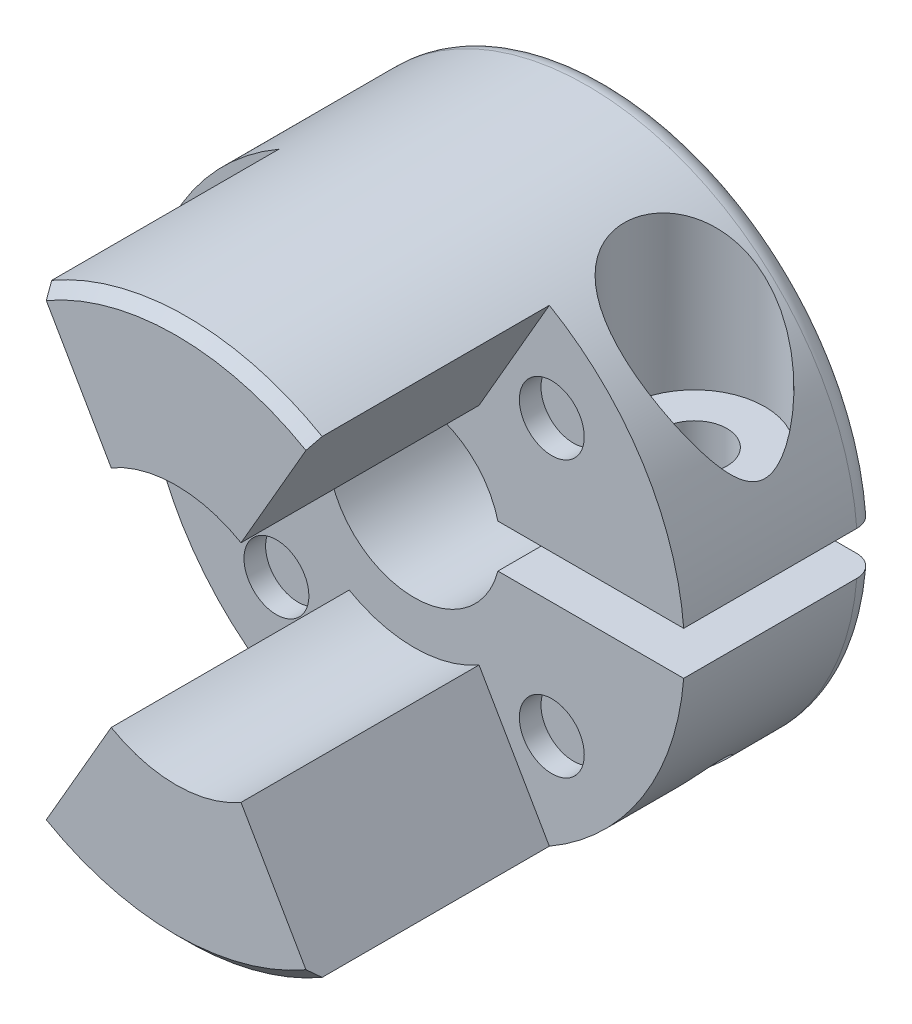
from build123d import *

# Parameters (mm, degrees)
ESBO_O1_R                 = 12.5
RESSALTO_EXTRUS_O1_DEPTH  = 20
CORTE_EXTRUS_O3_DEPTH     = 11
ESBO_O3_R                 = 4
CORTE_EXTRUS_O4_DEPTH     = 21
ESBO_O6_W                 = 12
ESBO_O6_H                 = 2
CORTE_EXTRUS_O5_DEPTH     = 10
CORTE_EXTRUS_O6_START     = -3
ESBO_O7_R                 = 3.25
CORTE_EXTRUS_O6_DEPTH     = 9.5
FURO_ROSCADO_DE_M3X0_51_D = 2.5
FILETE1_R                 = 1
ESBO_O10_R                = 1.5
CORTE_EXTRUS_O7_DEPTH     = 1
CHANFRO1_SIZE             = 0.5
CORTE_EXTRUS_O8_REACH     = 18.5
ESBO_O11_R                = 1.5
ESBO_O12_R                = 6
CORTE_EXTRUS_O9_DEPTH     = 11
PADR_OCIRCULAR1_COUNT     = 4
CHANFRO2_SIZE             = 0.5


with BuildPart() as part:
    # Esboço1 → Ressalto-extrusão1 (new body)
    with BuildSketch(Plane.XY):
        Circle(ESBO_O1_R)
    extrude(amount=RESSALTO_EXTRUS_O1_DEPTH)

    # Esboço2 → Corte-extrusão3 (cut)
    with BuildSketch(Plane.XY.offset(20)):
        with BuildLine():
            Line((0, 0), (6.25, 10.825317547))
            ThreePointArc((6.25, 10.825317547), (12.5, 0), (6.25, -10.825317547))
            Line((6.25, -10.825317547), (0, 0))
        make_face()
    corte_extrus_o3 = extrude(amount=-CORTE_EXTRUS_O3_DEPTH, mode=Mode.SUBTRACT)

    # Esboço3 → Corte-extrusão4 (cut, through all)
    with BuildSketch(Plane(origin=(0, 0, 0), x_dir=(-1, 0, 0), z_dir=(0, 0, -1))):
        Circle(ESBO_O3_R)
    extrude(amount=-CORTE_EXTRUS_O4_DEPTH, mode=Mode.SUBTRACT)

    # Espelhar1: Corte-extrusão3 across plane
    add(corte_extrus_o3.mirror(Plane(origin=(0, 0, 0), x_dir=(0, 0, 1), z_dir=(1, 0, 0))), mode=Mode.SUBTRACT)

    # Esboço6 → Corte-extrusão5 (cut, through all)
    with BuildSketch(Plane.XY.offset(9)):
        with Locations((7, 0)):
            Rectangle(ESBO_O6_W, ESBO_O6_H)
    extrude(amount=-CORTE_EXTRUS_O5_DEPTH, mode=Mode.SUBTRACT)

    # Esboço7 → Corte-extrusão6 (cut, through all)
    with BuildSketch(Plane.XZ.offset(-1).offset(CORTE_EXTRUS_O6_START)):
        with Locations((8.459935794, 4.5)):
            Circle(ESBO_O7_R)
    extrude(amount=-CORTE_EXTRUS_O6_DEPTH, mode=Mode.SUBTRACT)

    # Furo roscado de M3x0.51 (through all)
    with Locations(Plane(origin=(0, 4, 0), x_dir=(1, 0, 0), z_dir=(0, 1, 0))):
        with Locations((8.459935794, -4.5)):
            Hole(FURO_ROSCADO_DE_M3X0_51_D / 2)

    # Filete1
    filete1_edges = [part.edges().sort_by_distance(p)[0] for p in [
        (-12.5, 0, 0),
    ]]
    fillet(filete1_edges, radius=FILETE1_R)

    # Esboço10 → Corte-extrusão7 (cut)
    with BuildSketch(Plane.XY.offset(9)):
        with Locations((6.363961031, -6.363961031)):
            Circle(ESBO_O10_R)
    corte_extrus_o7 = extrude(amount=-CORTE_EXTRUS_O7_DEPTH, mode=Mode.SUBTRACT)

    # Chanfro1
    chanfro1_edges = [part.edges().sort_by_distance(p)[0] for p in [
        (0, -12.5, 20),
        (0, 12.5, 20),
    ]]
    chamfer(chanfro1_edges, length=CHANFRO1_SIZE)

    # Esboço11 → Corte-extrusão8 (cut, up to next)
    with BuildSketch(Plane(origin=(0, 4, 0), x_dir=(1, 0, 0), z_dir=(0, 1, 0)), mode=Mode.PRIVATE) as corte_extrus_o8_sk1:
        with Locations((8.459935794, -4.5)):
            Circle(ESBO_O11_R)
    corte_extrus_o8_tool1 = extrude(corte_extrus_o8_sk1.sketch, amount=-CORTE_EXTRUS_O8_REACH, mode=Mode.PRIVATE) & part.part
    add(corte_extrus_o8_tool1.solids().sort_by_distance((8.459936, 4, 4.5))[0], mode=Mode.SUBTRACT)

    # Esboço12 → Corte-extrusão9 (cut)
    with BuildSketch(Plane.XY.offset(20)):
        Circle(ESBO_O12_R)
    extrude(amount=-CORTE_EXTRUS_O9_DEPTH, mode=Mode.SUBTRACT)

    # PadrãoCircular1: Corte-extrusão7 ×4 about axis
    padr_ocircular1_axis = Axis((0, 0, 0), (0, 0, 1))
    for i in range(1, PADR_OCIRCULAR1_COUNT):
        add(corte_extrus_o7.rotate(padr_ocircular1_axis, i * 360 / PADR_OCIRCULAR1_COUNT), mode=Mode.SUBTRACT)

    # Chanfro2
    chanfro2_edges = [part.edges().sort_by_distance(p)[0] for p in [
        (-4, 0, 0),
    ]]
    chamfer(chanfro2_edges, length=CHANFRO2_SIZE)


solid = part.part
